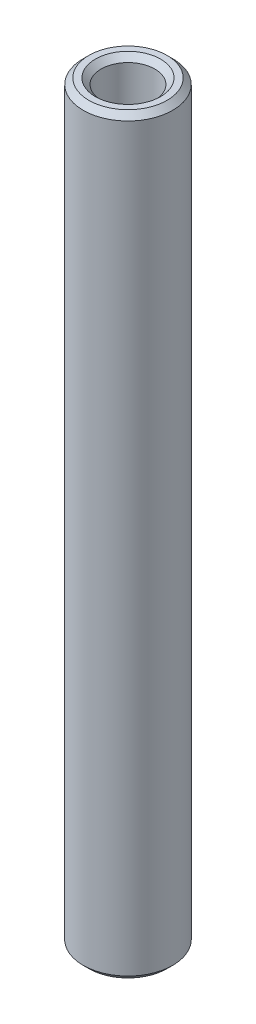
from build123d import *

# Parameters (mm, degrees)
SKETCH1_R           = 1.984375
SKETCH1_R_2         = 1.190625
BOSS_EXTRUDE1_DEPTH = 16.66875
CHAMFER1_SIZE       = 0.254


with BuildPart() as part:
    # Sketch1 → Boss-Extrude1 (new body, symmetric)
    with BuildSketch(Plane(origin=(0, 0, 0), x_dir=(1, 0, 0), z_dir=(0, 1, 0))):
        Circle(SKETCH1_R)
        Circle(SKETCH1_R_2, mode=Mode.SUBTRACT)
    extrude(amount=BOSS_EXTRUDE1_DEPTH, both=True)

    # Chamfer1
    chamfer1_edges = [part.edges().sort_by_distance(p)[0] for p in [
        (-1.984375, -16.66875, 0),
        (-1.984375, 16.66875, 0),
        (-1.190625, -16.66875, 0),
        (-1.190625, 16.66875, 0),
    ]]
    chamfer(chamfer1_edges, length=CHAMFER1_SIZE)


solid = part.part
